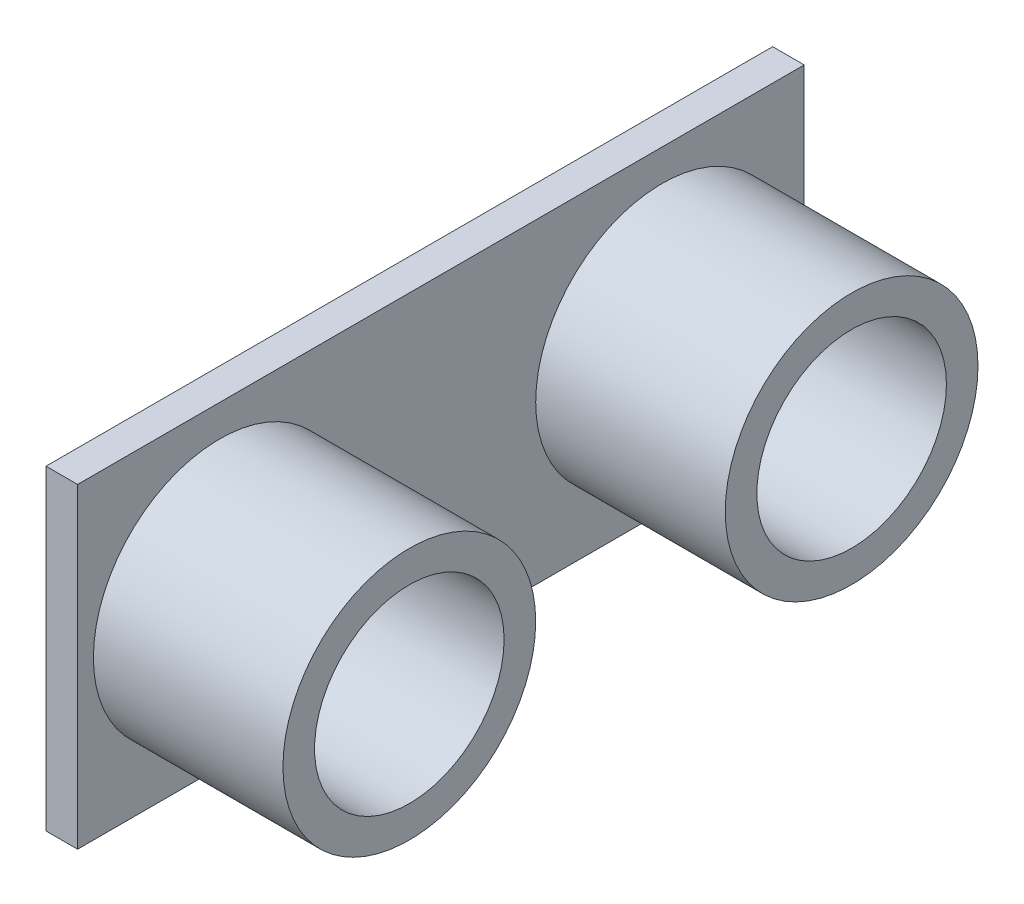
from build123d import *

# Parameters (mm, degrees)
SKETCH1_W           = 46
SKETCH1_H           = 20
BOSS_EXTRUDE1_DEPTH = 1
SKETCH2_R           = 8
SKETCH2_R_2         = 6
BOSS_EXTRUDE2_DEPTH = 12
SKETCH3_W           = 5.881600094
SKETCH3_H           = 1.447060341
BOSS_EXTRUDE3_DEPTH = 5


with BuildPart() as part:
    # Sketch1 → Boss-Extrude1 (new body, symmetric)
    with BuildSketch(Plane(origin=(0, 0, 0), x_dir=(0, 0, -1), z_dir=(1, 0, 0))):
        with Locations((23, 10)):
            Rectangle(SKETCH1_W, SKETCH1_H)
    extrude(amount=BOSS_EXTRUDE1_DEPTH, both=True)

    # Sketch2 → Boss-Extrude2 (add)
    with BuildSketch(Plane(origin=(1, 0, 0), x_dir=(0, 0, -1), z_dir=(1, 0, 0))):
        with Locations((9, 10)):
            Circle(SKETCH2_R)
        with Locations((9, 10)):
            Circle(SKETCH2_R_2, mode=Mode.SUBTRACT)
        with Locations((37, 10)):
            Circle(SKETCH2_R)
        with Locations((37, 10)):
            Circle(SKETCH2_R_2, mode=Mode.SUBTRACT)
    extrude(amount=BOSS_EXTRUDE2_DEPTH)

    # Sketch3 → Boss-Extrude3 (add)
    with BuildSketch(Plane.ZY.offset(1)):
        with Locations((-22.486526976, 0.723530171)):
            Rectangle(SKETCH3_W, SKETCH3_H)
    extrude(amount=BOSS_EXTRUDE3_DEPTH)


solid = part.part
